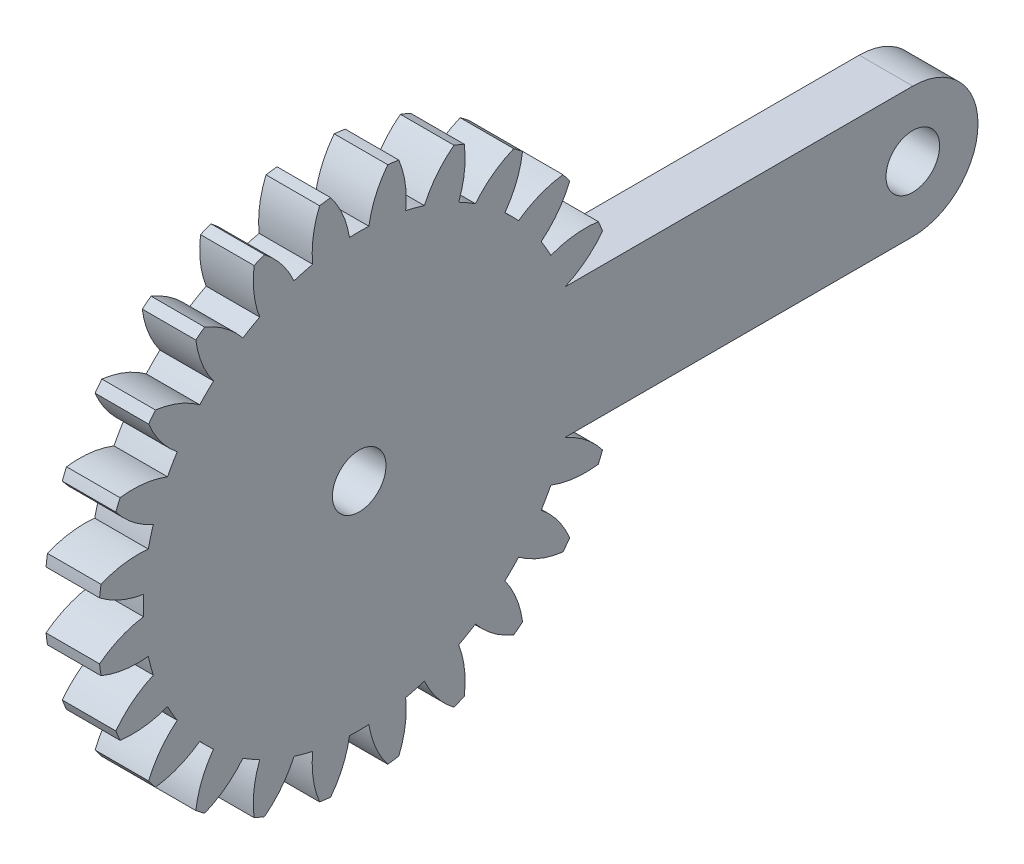
from build123d import *

# Parameters (mm, degrees)
BASPROSKE_W         = 3
BASPROSKE_H         = 14.625
TOOTHCUT_DEPTH      = 21.89931219
TEETHCUTS_COUNT     = 24
TEETHCUTS_ANGLE     = 345
BORSKE_R            = 1.5
BORE_DEPTH          = 50.0000508
SKETCH1_R           = 1.5
BOSS_EXTRUDE1_DEPTH = 3


with BuildPart() as part:
    # BasProSke → Base-Revolve (revolve)
    with BuildSketch(Plane(origin=(0, 0, 0), x_dir=(1, 0, 0), z_dir=(0, 1, 0)), mode=Mode.PRIVATE) as base_revolve_sk:
        with Locations((1.5, 7.3125)):
            Rectangle(BASPROSKE_W, BASPROSKE_H)
    revolve(base_revolve_sk.sketch.rotate(Axis((-10, 0, 0), (1, 0, 0)), 180), axis=Axis((-10, 0, 0), (1, 0, 0)))

    # TooCutSke → ToothCut (cut, through all)
    with BuildSketch(Plane(origin=(0, 0, 0), x_dir=(0, 0, -1), z_dir=(1, 0, 0))):
        with BuildLine():
            ThreePointArc((0.542722358, 12.080565177), (0, 12.09275), (-0.542722358, 12.080565177))
            ThreePointArc((-0.542722358, 12.080565177), (-0.922320579, 13.38903626), (-1.617327261, 14.56085412))
            ThreePointArc((-1.617327261, 14.56085412), (0, 14.6504), (1.617327261, 14.56085412))
            ThreePointArc((1.617327261, 14.56085412), (0.922320579, 13.38903626), (0.542722358, 12.080565177))
        make_face()
    toothcut = extrude(amount=TOOTHCUT_DEPTH, mode=Mode.SUBTRACT)

    # TeethCuts: ToothCut ×24 about axis
    teethcuts_axis = Axis((-10, 0, 0), (1, 0, 0))
    for i in range(1, TEETHCUTS_COUNT):
        add(toothcut.rotate(teethcuts_axis, i * TEETHCUTS_ANGLE / (TEETHCUTS_COUNT - 1)), mode=Mode.SUBTRACT)

    # BorSke → Bore (cut, symmetric)
    with BuildSketch(Plane(origin=(0, 0, 0), x_dir=(0, 0, -1), z_dir=(1, 0, 0))):
        with Locations(Location((0, 0, 0), (0, 0, 180))):
            Circle(BORSKE_R)
    extrude(amount=BORE_DEPTH, both=True, mode=Mode.SUBTRACT)

    # Sketch1 → Boss-Extrude1 (add)
    with BuildSketch(Plane(origin=(0, 0, 0), x_dir=(0, 0, -1), z_dir=(1, 0, 0))):
        with BuildLine():
            Line((31, 3.650909885), (11.528463019, 3.650909885))
            Line((11.528463019, 3.650909885), (11.528463019, -3.650909885))
            Line((11.528463019, -3.650909885), (31, -3.650909885))
            ThreePointArc((31, -3.650909885), (34.650909885, 0), (31, 3.650909885))
        make_face()
        with Locations((31, 0)):
            Circle(SKETCH1_R, mode=Mode.SUBTRACT)
    extrude(amount=BOSS_EXTRUDE1_DEPTH)


solid = part.part
